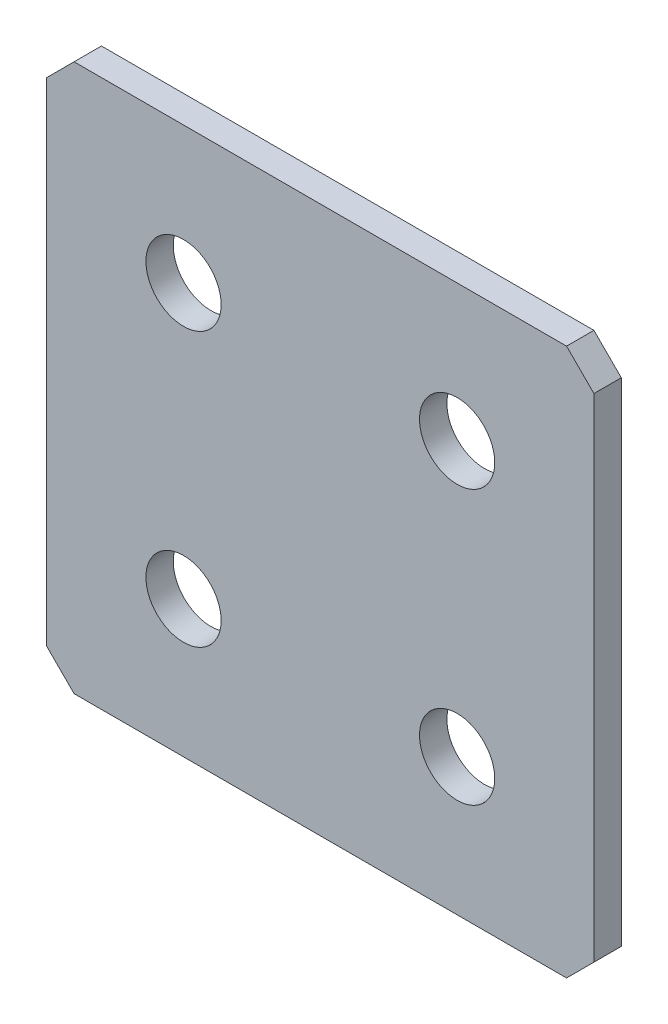
from build123d import *

# Parameters (mm, degrees)
SKETCH_1_W        = 40
SKETCH_1_H        = 40
EXTRUDE_1_DEPTH   = 2
CHAMFER_1_SIZE    = 2
HOLE_WIZARD_M51_D = 5.5


with BuildPart() as part:
    # Эскиз1 → Бобышка-Вытянуть1 (new body)
    with BuildSketch(Plane.XY):
        Rectangle(SKETCH_1_W, SKETCH_1_H)
    extrude(amount=EXTRUDE_1_DEPTH)

    # Фаска1
    chamfer_1_edges = [part.edges().sort_by_distance(p)[0] for p in [
        (20, -20, 1),
        (-20, -20, 1),
        (-20, 20, 1),
        (20, 20, 1),
    ]]
    chamfer(chamfer_1_edges, length=CHAMFER_1_SIZE)

    # Отверстие с зазором M51 (through all)
    with Locations(Plane.XY.offset(2)):
        with Locations((-10, 10), (10, 10), (-10, -10), (10, -10), (-10, 30), (10, 30), (10, -30), (-10, -30)):
            Hole(HOLE_WIZARD_M51_D / 2)


solid = part.part
